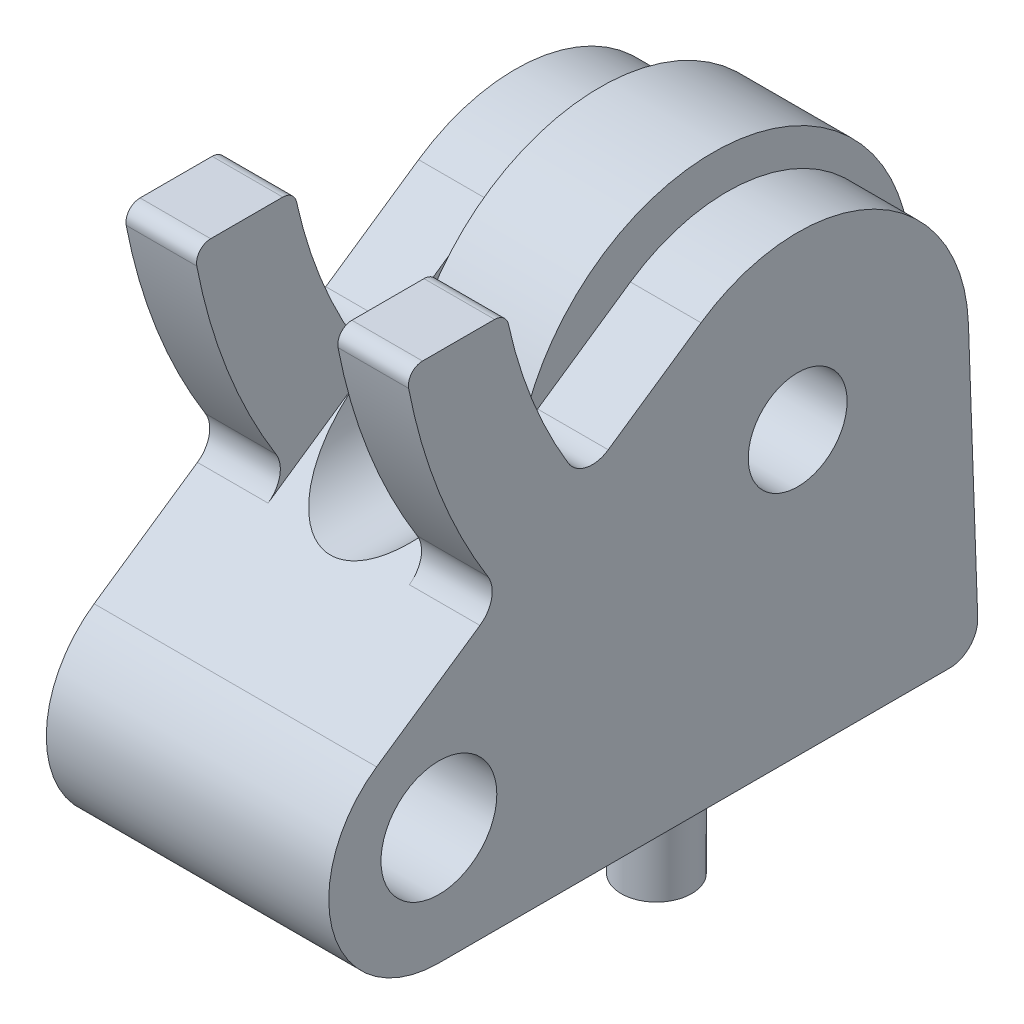
from build123d import *

# Parameters (mm, degrees)
BOSS_EXTRUDE3_DEPTH      = 5
BOSS_EXTRUDE3_DEPTH_BACK = 5
SKETCH2_R                = 2.05
BOSS_EXTRUDE1_START      = 2.5
SKETCH1_R                = 2.05
SKETCH1_R_2              = 1.75
BOSS_EXTRUDE1_DEPTH      = 2.5
SKETCH4_R                = 2.5
CUT_EXTRUDE1_DEPTH       = 21
SKETCH6_R                = 1.7
BOSS_EXTRUDE4_DEPTH      = 2.9
SKETCH7_R                = 1.25
BOSS_EXTRUDE5_DEPTH      = 3.2
BOSS_EXTRUDE6_DEPTH      = 2
BOSS_EXTRUDE6_DEPTH_BACK = 2
SKETCH8_R                = 7


with BuildPart() as part:
    # Sketch2 → Boss-Extrude3 (new, two sides: drawn at the far end of the back side and taken through both)
    with BuildSketch(Plane(origin=(0, 0, 0), x_dir=(0, 0, -1), z_dir=(1, 0, 0)).offset(-BOSS_EXTRUDE3_DEPTH_BACK)):
        with BuildLine():
            Line((4.807685332, 11.924515372), (4.807685332, 2.1))
            Line((4.807685332, 2.1), (19.036259504, 2.1))
            Line((19.036259504, 2.1), (19.074303405, 1.035723438))
            ThreePointArc((19.074303405, 1.035723438), (18.794567787, 0.30563822), (18.074941691, 0))
            Line((18.074941691, 0), (0, 0))
            ThreePointArc((0, 0), (-3.725249554, 2.745653536), (-2.205245462, 7.116658585))
            Line((-2.205245462, 7.116658585), (4.807685332, 11.924515372))
        make_face()
        with Locations((0, 4.15)):
            Circle(SKETCH2_R, mode=Mode.SUBTRACT)
    extrude(amount=BOSS_EXTRUDE3_DEPTH + BOSS_EXTRUDE3_DEPTH_BACK)

    # Sketch1 → Boss-Extrude1 (add)
    with BuildSketch(Plane(origin=(0, 0, 0), x_dir=(0, 0, -1), z_dir=(1, 0, 0)).offset(BOSS_EXTRUDE1_START)):
        with BuildLine():
            Line((0, 0), (18.074941691, 0))
            ThreePointArc((18.074941691, 0), (18.794567787, 0.30563822), (19.074303405, 1.035723438))
            Line((19.074303405, 1.035723438), (18.746138371, 10.2161268))
            ThreePointArc((18.746138371, 10.2161268), (15.424009506, 15.402061848), (9.279042296, 14.989944728))
            Line((9.279042296, 14.989944728), (5.994198358, 12.737953415))
            ThreePointArc((5.994198358, 12.737953415), (5.215965086, 12.585638779), (4.571541427, 13.047769626))
            ThreePointArc((4.571541427, 13.047769626), (3.300176399, 15.61485789), (2.460196394, 18.353606653))
            ThreePointArc((2.460196394, 18.353606653), (2.285157974, 18.635892094), (1.971865395, 18.746215613))
            Line((1.971865395, 18.746215613), (-0.58043143, 18.746215613))
            ThreePointArc((-0.58043143, 18.746215613), (-0.965919929, 18.564647109), (-1.071438147, 18.151810083))
            ThreePointArc((-1.071438147, 18.151810083), (0.003024945, 14.435267981), (1.735735032, 10.976240389))
            ThreePointArc((1.735735032, 10.976240389), (1.864947174, 10.243059004), (1.451738268, 9.623777871))
            Line((1.451738268, 9.623777871), (-2.205245462, 7.116658585))
            ThreePointArc((-2.205245462, 7.116658585), (-3.725249554, 2.745653536), (0, 0))
        make_face()
        with Locations((0, 4.15)):
            Circle(SKETCH1_R, mode=Mode.SUBTRACT)
        with Locations((12.7, 10)):
            Circle(SKETCH1_R_2, mode=Mode.SUBTRACT)
    boss_extrude1 = extrude(amount=BOSS_EXTRUDE1_DEPTH)

    # Mirror2: Boss-Extrude1 across plane
    add(boss_extrude1.mirror(Plane(origin=(0, 0, 0), x_dir=(0, 0, 1), z_dir=(1, 0, 0))))

    # Sketch4 → Cut-Extrude1 (cut)
    with BuildSketch(Plane.XY):
        with Locations((0, 11.924515372)):
            Circle(SKETCH4_R)
    extrude(amount=-CUT_EXTRUDE1_DEPTH, mode=Mode.SUBTRACT)

    # Sketch6 → Boss-Extrude4 (add)
    with BuildSketch(Plane.XZ):
        with Locations((0, -12.7)):
            Circle(SKETCH6_R)
    extrude(amount=BOSS_EXTRUDE4_DEPTH)

    # Sketch7 → Boss-Extrude5 (add)
    with BuildSketch(Plane.XZ.offset(2.9)):
        with Locations((0, -12.7)):
            Circle(SKETCH7_R)
    extrude(amount=BOSS_EXTRUDE5_DEPTH)


with BuildPart() as body_2:
    # Sketch8 → Boss-Extrude6 (new, two sides: drawn at the far end of the back side and taken through both)
    with BuildSketch(Plane(origin=(0, 0, 0), x_dir=(0, 0, -1), z_dir=(1, 0, 0)).offset(-BOSS_EXTRUDE6_DEPTH_BACK)):
        with Locations((12.7, 10)):
            Circle(SKETCH8_R)
    extrude(amount=BOSS_EXTRUDE6_DEPTH + BOSS_EXTRUDE6_DEPTH_BACK)


solid = Compound([part.part, body_2.part])
